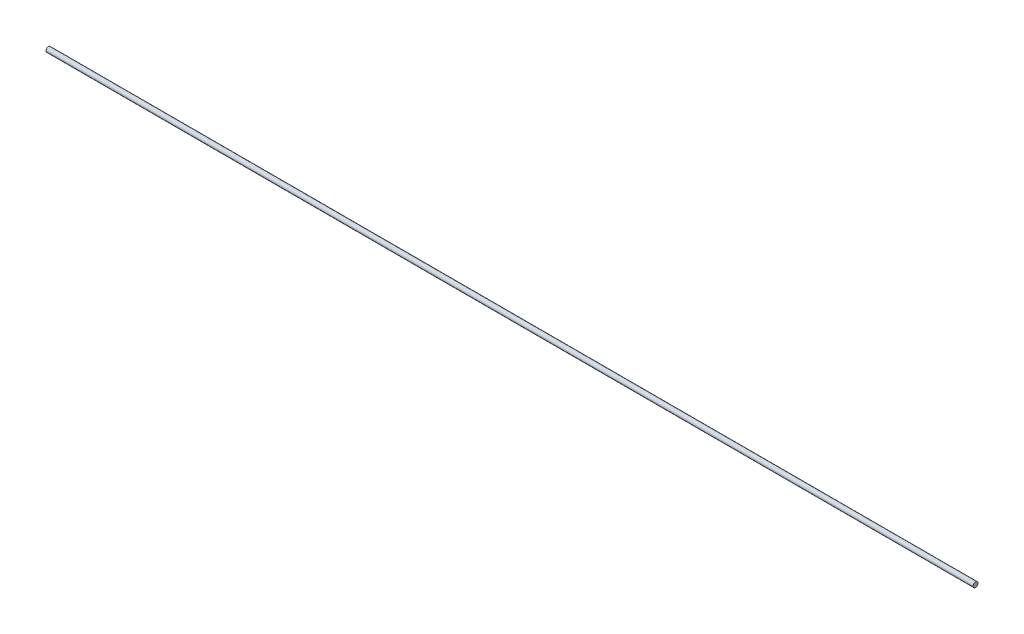
from build123d import *

# Parameters (mm, degrees)
SKETCH1_R           = 1
BOSS_EXTRUDE1_DEPTH = 380


with BuildPart() as part:
    # Sketch1 → Boss-Extrude1 (new body)
    with BuildSketch(Plane(origin=(0, 0, 0), x_dir=(0, 0, -1), z_dir=(1, 0, 0))):
        Circle(SKETCH1_R)
    extrude(amount=BOSS_EXTRUDE1_DEPTH)


solid = part.part
